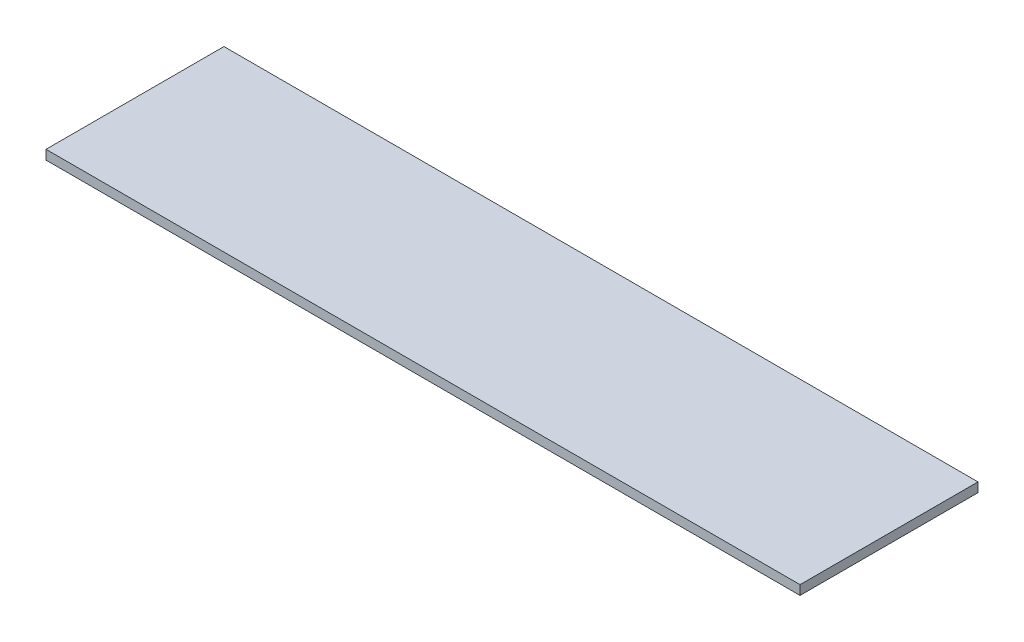
from build123d import *

# Parameters (mm, degrees)
SKETCH1_W           = 511.175
SKETCH1_H           = 120.65
BOSS_EXTRUDE1_DEPTH = 6.35


with BuildPart() as part:
    # Sketch1 → Boss-Extrude1 (new body)
    with BuildSketch(Plane(origin=(0, 0, 0), x_dir=(1, 0, 0), z_dir=(0, 1, 0))):
        with Locations((255.5875, 60.325)):
            Rectangle(SKETCH1_W, SKETCH1_H)
    extrude(amount=BOSS_EXTRUDE1_DEPTH)


solid = part.part
